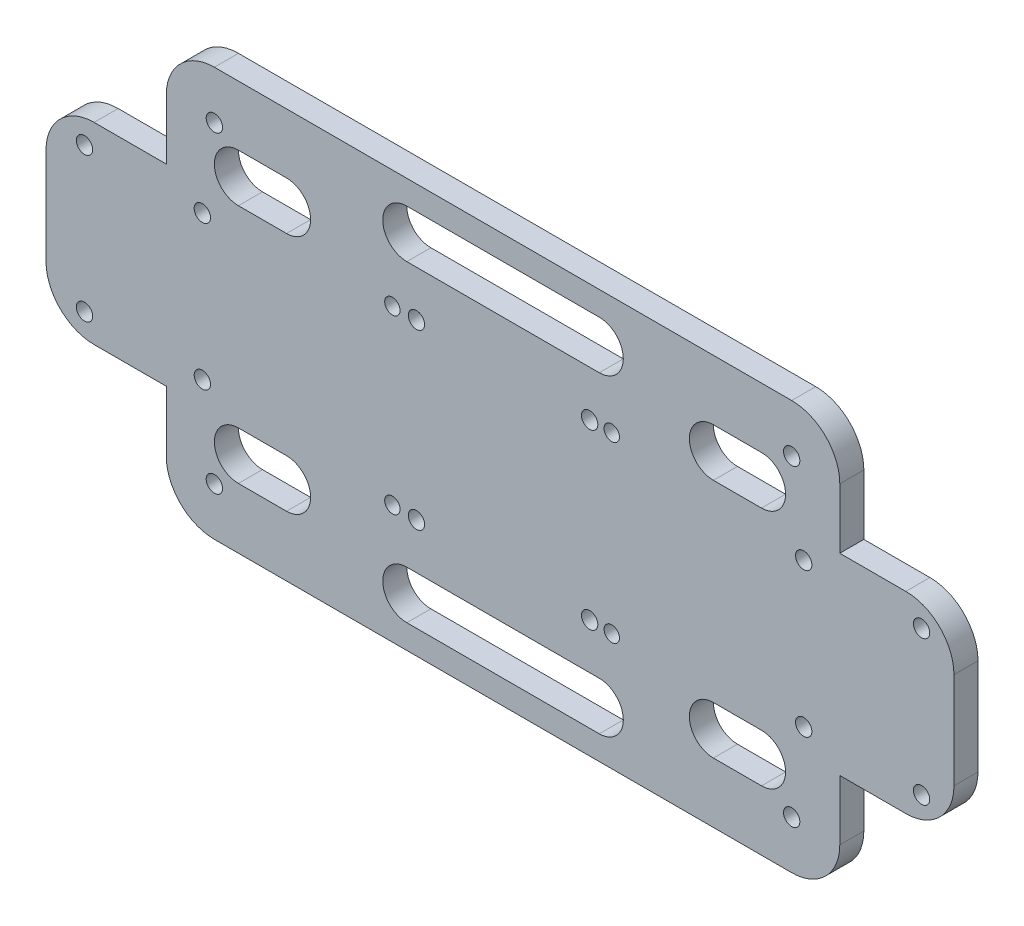
from build123d import *

# Parameters (mm, degrees)
SKETCH1_R           = 1.7
BOSS_EXTRUDE1_DEPTH = 5
CUT_EXTRUDE4_DEPTH  = 5
SKETCH3_R           = 1.6
SKETCH3_R_2         = 1.7
CUT_EXTRUDE7_DEPTH  = 5


with BuildPart() as part:
    # Sketch1 → Boss-Extrude1 (new body)
    with BuildSketch(Plane.XY):
        with BuildLine():
            Line((-60, 42.5), (60, 42.5))
            ThreePointArc((60, 42.5), (67.071067812, 39.571067812), (70, 32.5))
            Line((70, 32.5), (70, 20))
            Line((70, 20), (83.73, 20))
            ThreePointArc((83.73, 20), (90.801067812, 17.071067812), (93.73, 10))
            Line((93.73, 10), (93.73, -10))
            ThreePointArc((93.73, -10), (90.801067812, -17.071067812), (83.73, -20))
            Line((83.73, -20), (70, -20))
            Line((70, -20), (70, -32.5))
            ThreePointArc((70, -32.5), (67.071067812, -39.571067812), (60, -42.5))
            Line((60, -42.5), (-60, -42.5))
            ThreePointArc((-60, -42.5), (-67.071067812, -39.571067812), (-70, -32.5))
            Line((-70, -32.5), (-70, -19.935858434))
            Line((-70, -19.935858434), (-85, -19.935858434))
            ThreePointArc((-85, -19.935858434), (-92.071067812, -17.006926246), (-95, -9.935858434))
            Line((-95, -9.935858434), (-95, 10.064141566))
            ThreePointArc((-95, 10.064141566), (-92.071067812, 17.135209378), (-85, 20.064141566))
            Line((-85, 20.064141566), (-70, 20.064141566))
            Line((-70, 20.064141566), (-70, 32.5))
            ThreePointArc((-70, 32.5), (-67.071067812, 39.571067812), (-60, 42.5))
        make_face()
        with Locations((-87, 15)):
            Circle(SKETCH1_R, mode=Mode.SUBTRACT)
        with Locations((-62.5, 15)):
            Circle(SKETCH1_R, mode=Mode.SUBTRACT)
        with Locations((-62.5, -15)):
            Circle(SKETCH1_R, mode=Mode.SUBTRACT)
        with Locations((-87, -15)):
            Circle(SKETCH1_R, mode=Mode.SUBTRACT)
        with Locations((62.5, 15)):
            Circle(SKETCH1_R, mode=Mode.SUBTRACT)
        with Locations((62.5, -15)):
            Circle(SKETCH1_R, mode=Mode.SUBTRACT)
        with Locations((87, -15)):
            Circle(SKETCH1_R, mode=Mode.SUBTRACT)
        with Locations((87, 15)):
            Circle(SKETCH1_R, mode=Mode.SUBTRACT)
        with Locations((-60, 32.5)):
            Circle(SKETCH1_R, mode=Mode.SUBTRACT)
        with Locations((60, 32.5)):
            Circle(SKETCH1_R, mode=Mode.SUBTRACT)
        with Locations((60, -32.5)):
            Circle(SKETCH1_R, mode=Mode.SUBTRACT)
        with Locations((-60, -32.5)):
            Circle(SKETCH1_R, mode=Mode.SUBTRACT)
    extrude(amount=BOSS_EXTRUDE1_DEPTH)

    # Sketch2 → Cut-Extrude4 (cut)
    with BuildSketch(Plane.XY):
        with BuildLine():
            Line((20, 37.5), (-20, 37.5))
            ThreePointArc((-20, 37.5), (-25, 32.5), (-20, 27.5))
            Line((-20, 27.5), (20, 27.5))
            ThreePointArc((20, 27.5), (25, 32.5), (20, 37.5))
        make_face()
        with BuildLine():
            Line((20, -27.5), (-20, -27.5))
            ThreePointArc((-20, -27.5), (-25, -32.5), (-20, -37.5))
            Line((-20, -37.5), (20, -37.5))
            ThreePointArc((20, -37.5), (25, -32.5), (20, -27.5))
        make_face()
        with BuildLine():
            Line((-45, 30.064141566), (-55, 30.064141566))
            ThreePointArc((-55, 30.064141566), (-60, 25.064141566), (-55, 20.064141566))
            Line((-55, 20.064141566), (-45, 20.064141566))
            ThreePointArc((-45, 20.064141566), (-40, 25.064141566), (-45, 30.064141566))
        make_face()
        with BuildLine():
            Line((-45, -19.935858434), (-55, -19.935858434))
            ThreePointArc((-55, -19.935858434), (-60, -24.935858434), (-55, -29.935858434))
            Line((-55, -29.935858434), (-45, -29.935858434))
            ThreePointArc((-45, -29.935858434), (-40, -24.935858434), (-45, -19.935858434))
        make_face()
        with BuildLine():
            Line((53.73, 30), (43.73, 30))
            ThreePointArc((43.73, 30), (38.73, 25), (43.73, 20))
            Line((43.73, 20), (53.73, 20))
            ThreePointArc((53.73, 20), (58.73, 25), (53.73, 30))
        make_face()
        with BuildLine():
            Line((53.73, -20), (43.73, -20))
            ThreePointArc((43.73, -20), (38.73, -25), (43.73, -30))
            Line((43.73, -30), (53.73, -30))
            ThreePointArc((53.73, -30), (58.73, -25), (53.73, -20))
        make_face()
    extrude(amount=CUT_EXTRUDE4_DEPTH, mode=Mode.SUBTRACT)

    # Sketch3 → Cut-Extrude7 (cut)
    with BuildSketch(Plane.XY):
        with Locations((-23, -17.8)):
            Circle(SKETCH3_R)
        with Locations((-23, 18)):
            Circle(SKETCH3_R)
        with Locations((22.6, -18.168627451)):
            Circle(SKETCH3_R)
        with Locations((22.6, 18)):
            Circle(SKETCH3_R)
        with Locations((-18, 18)):
            Circle(SKETCH3_R_2)
        with Locations((18, -18)):
            Circle(SKETCH3_R_2)
        with Locations((-18, -18)):
            Circle(SKETCH3_R_2)
        with Locations((18, 18)):
            Circle(SKETCH3_R_2)
    extrude(amount=CUT_EXTRUDE7_DEPTH, mode=Mode.SUBTRACT)


solid = part.part
